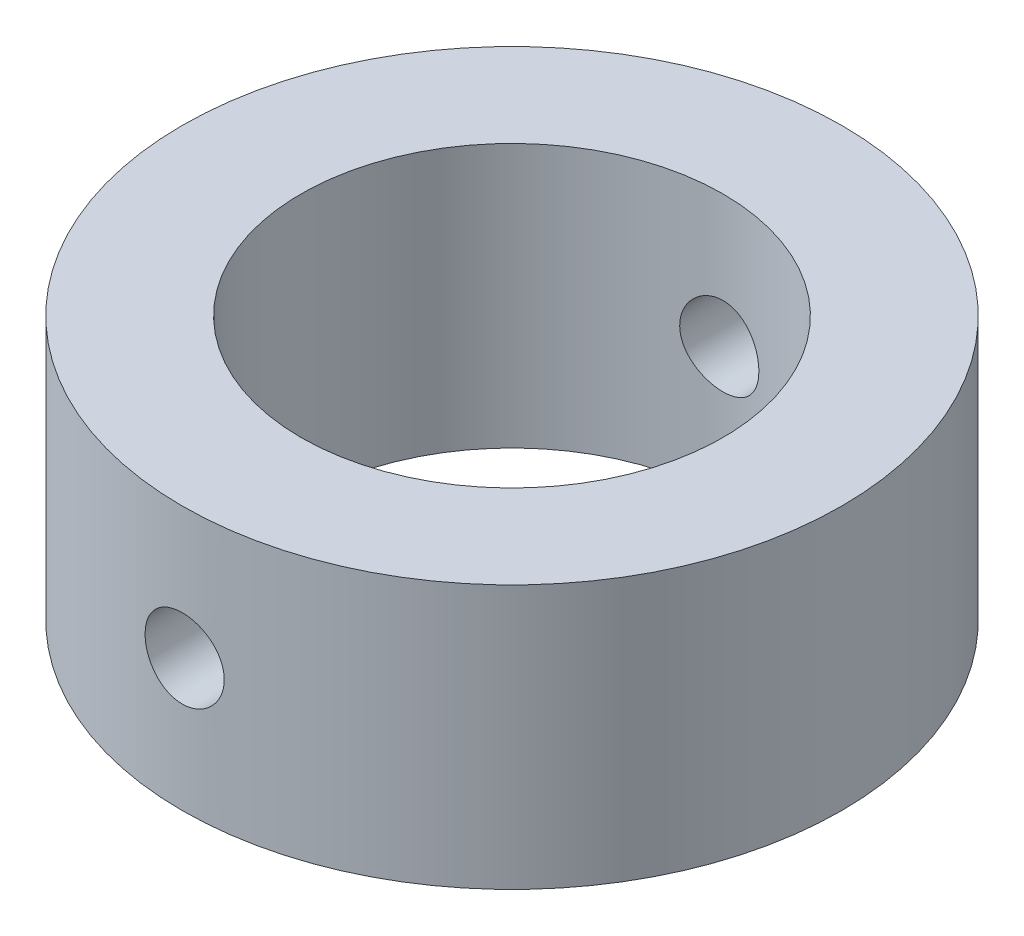
from build123d import *

# Parameters (mm, degrees)
SKETCH2_R               = 12.5
BOSS_EXTRUDE1_DEPTH     = 10
SKETCH3_R               = 8
CUT_EXTRUDE1_DEPTH      = 10
SKETCH5_R               = 1.5
CUT_EXTRUDE2_DEPTH      = 13.5
CUT_EXTRUDE2_DEPTH_BACK = 13.5
SCALE1_SCALE            = 2


with BuildPart() as part:
    # Sketch2 → Boss-Extrude1 (new body)
    with BuildSketch(Plane(origin=(0, 0, 0), x_dir=(1, 0, 0), z_dir=(0, 1, 0))):
        Circle(SKETCH2_R)
    extrude(amount=BOSS_EXTRUDE1_DEPTH)

    # Sketch3 → Cut-Extrude1 (cut)
    with BuildSketch(Plane(origin=(0, 10, 0), x_dir=(1, 0, 0), z_dir=(0, 1, 0))):
        Circle(SKETCH3_R)
    extrude(amount=-CUT_EXTRUDE1_DEPTH, mode=Mode.SUBTRACT)

    # Sketch5 → Cut-Extrude2 (cut, two sides)
    with BuildSketch(Plane.XY) as cut_extrude2_sk:
        with Locations((0, 5)):
            Circle(SKETCH5_R)
    extrude(amount=CUT_EXTRUDE2_DEPTH, mode=Mode.SUBTRACT)
    extrude(cut_extrude2_sk.sketch, amount=-CUT_EXTRUDE2_DEPTH_BACK, mode=Mode.SUBTRACT)


with BuildPart() as part_1:
    # Scale1: scaled about (1.973e-06, 5.000003293, 0)
    add(part.part.scale(SCALE1_SCALE).moved(Location((-1.973e-06, -5.000003293, 0))))


solid = part_1.part
